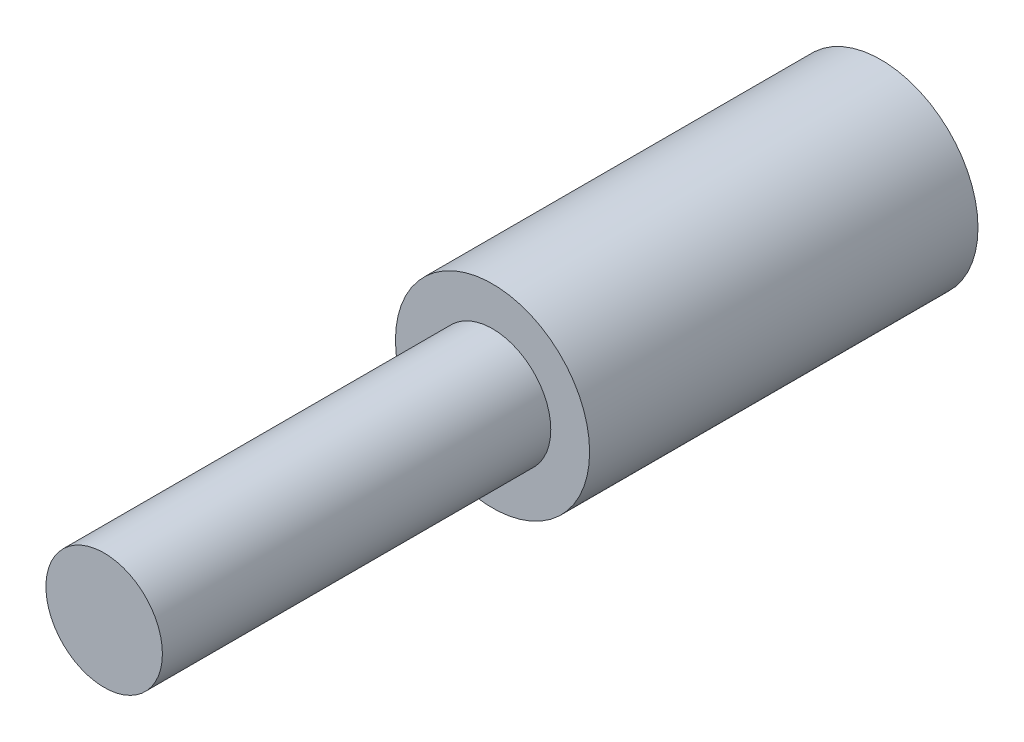
from build123d import *

# Parameters (mm, degrees)
SKIZZE1_R                       = 25
AUFSATZ_LINEAR_AUSTRAGEN1_DEPTH = 100
SKIZZE2_R                       = 15
AUFSATZ_LINEAR_AUSTRAGEN2_DEPTH = 100


with BuildPart() as part:
    # Skizze1 → Aufsatz-Linear austragen1 (new body)
    with BuildSketch(Plane.XY):
        Circle(SKIZZE1_R)
    extrude(amount=AUFSATZ_LINEAR_AUSTRAGEN1_DEPTH)

    # Skizze2 → Aufsatz-Linear austragen2 (add)
    with BuildSketch(Plane.XY.offset(100)):
        Circle(SKIZZE2_R)
    extrude(amount=AUFSATZ_LINEAR_AUSTRAGEN2_DEPTH)


solid = part.part
